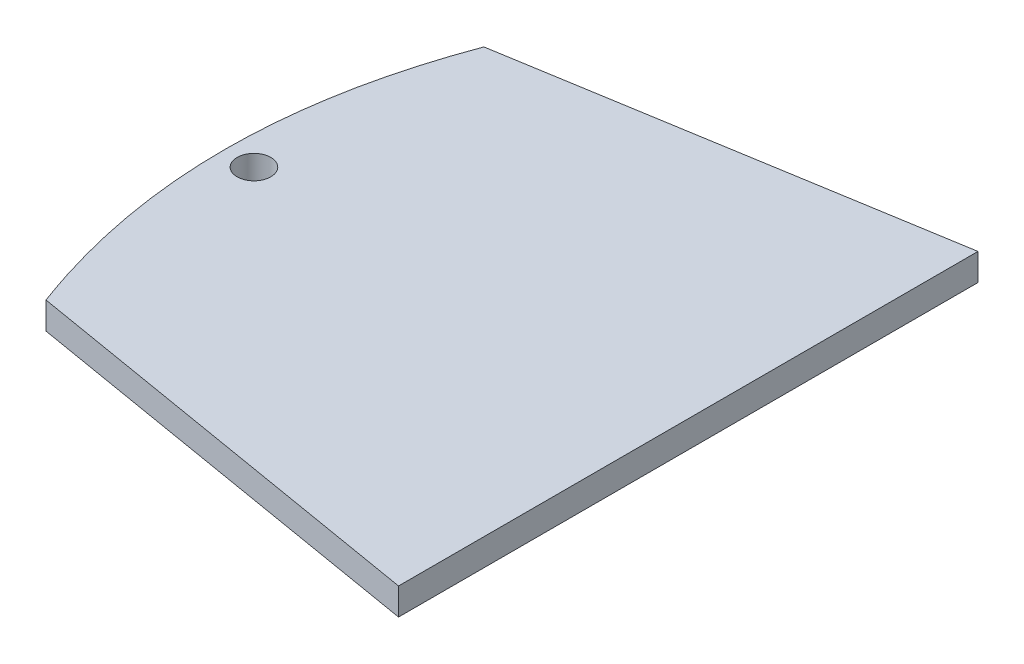
from build123d import *

# Parameters (mm, degrees)
CROQUIS2_R              = 2.5
SALIENTE_EXTRUIR1_DEPTH = 4


with BuildPart() as part:
    # Croquis2 → Saliente-Extruir1 (new body)
    with BuildSketch(Plane(origin=(0, 0, 0), x_dir=(1, 0, 0), z_dir=(0, 1, 0))):
        with BuildLine():
            Line((-79.601178676, 51.546233526), (-16.651724566, 61.929211291))
            Line((-16.651724566, 61.929211291), (-16.651724566, -24.070788709))
            Line((-16.651724566, -24.070788709), (-79.565967679, -13.476544348))
            add(Edge.make_bspline(
                [(-79.601178676, 51.546233526), (-91.719874733, 19.028313012), (-79.565967679, -13.476544348)],
                knots=[0, 0, 0, 1, 1, 1], degree=2))
        make_face()
        with Locations((-81.212594438, 19.032720929)):
            Circle(CROQUIS2_R, mode=Mode.SUBTRACT)
    extrude(amount=SALIENTE_EXTRUIR1_DEPTH)


solid = part.part
